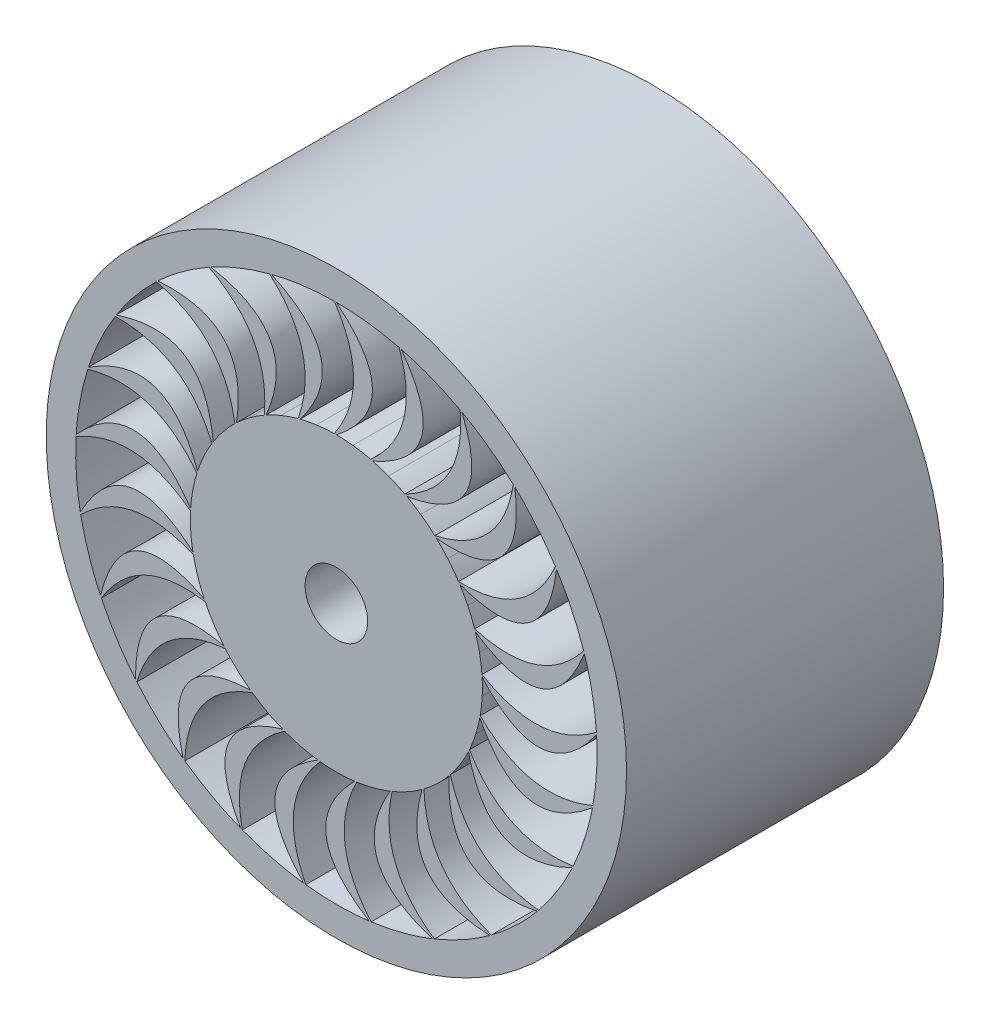
from build123d import *

# Parameters (mm, degrees)
SKETCH1_R           = 70
SKETCH1_R_2         = 50
BOSS_EXTRUDE1_DEPTH = 30
SKETCH2_R           = 70
SKETCH2_R_2         = 34
BOSS_EXTRUDE2_DEPTH = 92
SKETCH3_R           = 70
SKETCH3_R_2         = 15
BOSS_EXTRUDE3_DEPTH = 30
SKETCH5_R           = 139.105411196
SKETCH5_R_2         = 63.215067921
BOSS_EXTRUDE4_DEPTH = 152


with BuildPart() as part:
    # Sketch1 → Boss-Extrude1 (new body)
    with BuildSketch(Plane.XY):
        Circle(SKETCH1_R)
        Circle(SKETCH1_R_2, mode=Mode.SUBTRACT)
    extrude(amount=BOSS_EXTRUDE1_DEPTH)

    # Sketch2 → Boss-Extrude2 (add)
    with BuildSketch(Plane.XY.offset(30)):
        Circle(SKETCH2_R)
        Circle(SKETCH2_R_2, mode=Mode.SUBTRACT)
    extrude(amount=BOSS_EXTRUDE2_DEPTH)

    # Sketch3 → Boss-Extrude3 (add)
    with BuildSketch(Plane.XY.offset(122)):
        Circle(SKETCH3_R)
        Circle(SKETCH3_R_2, mode=Mode.SUBTRACT)
    extrude(amount=BOSS_EXTRUDE3_DEPTH)

    # Sketch5 → Boss-Extrude4 (add)
    with BuildSketch(Plane.XY.offset(152)):
        Circle(SKETCH5_R)
        Circle(SKETCH5_R_2, mode=Mode.SUBTRACT)
        with BuildLine():
            add(Edge.make_bspline(
                [(0, 125), (34.520668481, 97.000437143), (0, 70)],
                knots=[0, 0, 0, 1, 1, 1], degree=2))
            add(Edge.make_bspline(
                [(0, 70), (5.519813502, 69.962422729), (11.084458422, 69.380839885), (16.43970894, 68.049511166)],
                knots=[0.160000001, 0.160000001, 0.160000001, 0.160000001, 0.197721449, 0.197721449, 0.197721449, 0.197721449], degree=3))
            add(Edge.make_bspline(
                [(30.116665724, 121.317708706), (41.090840957, 89.926166343), (16.43970894, 68.049511166)],
                knots=[0, 0, 0, 1, 1, 1], degree=2))
            add(Edge.make_bspline(
                [(0, 125), (15.39585288, 124.97123946), (30.116665724, 121.317708706)],
                knots=[0, 0, 0, 0.0387732, 0.0387732, 0.0387732], degree=2))
        make_face(mode=Mode.SUBTRACT)
        with BuildLine():
            add(Edge.make_bspline(
                [(-0.999992, 124.996), (17.436168466, 97.319847066), (-1, 70)],
                knots=[0, 0, 0, 1, 1, 1], degree=2))
            add(Edge.make_bspline(
                [(-17.408292102, 67.800821279), (-12.052548604, 69.137146364), (-6.518093465, 69.957705932), (-1, 70)],
                knots=[0.120000001, 0.120000001, 0.120000001, 0.120000001, 0.157721449, 0.157721449, 0.157721449, 0.157721449], degree=3))
            add(Edge.make_bspline(
                [(-31.086235896, 121.072895141), (9.313110433, 102.537931188), (-17.408292102, 67.800821279)],
                knots=[0, 0, 0, 1, 1, 1], degree=2))
            add(Edge.make_bspline(
                [(-31.086235896, 121.072895141), (-16.395122569, 124.844074309), (-0.999992, 124.996)],
                knots=[0.961226801, 0.961226801, 0.961226801, 1, 1, 1], degree=2))
        make_face(mode=Mode.SUBTRACT)
        with BuildLine():
            add(Edge.make_bspline(
                [(31.086235896, 121.072895141), (57.559165969, 85.368048889), (17.408292102, 67.800821279)],
                knots=[0, 0, 0, 1, 1, 1], degree=2))
            add(Edge.make_bspline(
                [(17.408292102, 67.800821279), (22.745345426, 66.39170277), (27.990533021, 64.444520503), (32.846450507, 61.823221277)],
                knots=[0.200000001, 0.200000001, 0.200000001, 0.200000001, 0.237721449, 0.237721449, 0.237721449, 0.237721449], degree=3))
            add(Edge.make_bspline(
                [(59.340982578, 110.016579599), (62.163624788, 76.882093864), (32.846450507, 61.823221277)],
                knots=[0, 0, 0, 1, 1, 1], degree=2))
            add(Edge.make_bspline(
                [(31.086235896, 121.072895141), (40.884124984, 118.55665164), (50.438672273, 114.817678972), (59.340982578, 110.016579599)],
                knots=[0.040051117, 0.040051117, 0.040051117, 0.040051117, 0.078824317, 0.078824317, 0.078824317, 0.078824317], degree=3))
        make_face(mode=Mode.SUBTRACT)
        with BuildLine():
            add(Edge.make_bspline(
                [(60.219209263, 109.538335005), (76.981009372, 68.371672162), (33.722757187, 61.341467603)],
                knots=[0, 0, 0, 1, 1, 1], degree=2))
            add(Edge.make_bspline(
                [(33.722757187, 61.341467603), (38.541703642, 58.649347955), (43.137859486, 55.458914889), (47.189328788, 51.712351025)],
                knots=[0.240000001, 0.240000001, 0.240000001, 0.240000001, 0.277721449, 0.277721449, 0.277721449, 0.277721449], degree=3))
            add(Edge.make_bspline(
                [(84.836687257, 91.802704183), (79.330439453, 59.007236675), (47.189328788, 51.712351025)],
                knots=[0, 0, 0, 1, 1, 1], degree=2))
            add(Edge.make_bspline(
                [(60.219209263, 109.538335005), (69.08231109, 104.665148327), (77.408019168, 98.666896079), (84.836687257, 91.802704183)],
                knots=[0.080102234, 0.080102234, 0.080102234, 0.080102234, 0.118875434, 0.118875434, 0.118875434, 0.118875434], degree=3))
        make_face(mode=Mode.SUBTRACT)
        with BuildLine():
            add(Edge.make_bspline(
                [(85.568388241, 91.121078428), (91.56585284, 47.07925182), (47.918297415, 51.027803919)],
                knots=[0, 0, 0, 1, 1, 1], degree=2))
            add(Edge.make_bspline(
                [(47.918297415, 51.027803919), (51.916344875, 47.22183891), (55.574675592, 42.988621687), (58.56712799, 38.352203574)],
                knots=[0.280000001, 0.280000001, 0.280000001, 0.280000001, 0.317721449, 0.317721449, 0.317721449, 0.317721449], degree=3))
            add(Edge.make_bspline(
                [(105.001790868, 67.820527236), (91.512630849, 37.424737791), (58.56712799, 38.352203574)],
                knots=[0, 0, 0, 1, 1, 1], degree=2))
            add(Edge.make_bspline(
                [(85.568388241, 91.121078428), (92.94111503, 84.196834537), (99.513562902, 76.316502684), (105.001790868, 67.820527236)],
                knots=[0.120153351, 0.120153351, 0.120153351, 0.120153351, 0.15892655, 0.15892655, 0.15892655, 0.15892655], degree=3))
        make_face(mode=Mode.SUBTRACT)
        with BuildLine():
            add(Edge.make_bspline(
                [(105.540990688, 66.978349372), (100.397277018, 22.82866894), (59.102954785, 37.507875649)],
                knots=[0, 0, 0, 1, 1, 1], degree=2))
            add(Edge.make_bspline(
                [(59.102954785, 37.507875649), (62.028891223, 32.827208057), (64.51953044, 27.817195284), (66.264939146, 22.582246123)],
                knots=[0.320000001, 0.320000001, 0.320000001, 0.320000001, 0.357721449, 0.357721449, 0.357721449, 0.357721449], degree=3))
            add(Edge.make_bspline(
                [(118.569245789, 39.576937137), (97.94474709, 13.490704994), (66.264939146, 22.582246123)],
                knots=[0, 0, 0, 1, 1, 1], degree=2))
            add(Edge.make_bspline(
                [(105.540990688, 66.978349372), (110.960100153, 58.438120808), (115.36630377, 49.170862689), (118.569245789, 39.576937137)],
                knots=[0.160204467, 0.160204467, 0.160204467, 0.160204467, 0.198977667, 0.198977667, 0.198977667, 0.198977667], degree=3))
        make_face(mode=Mode.SUBTRACT)
        with BuildLine():
            add(Edge.make_bspline(
                [(118.882064537, 38.627124297), (102.920371046, -2.856323167), (66.573956141, 21.631189606)],
                knots=[0, 0, 0, 1, 1, 1], degree=2))
            add(Edge.make_bspline(
                [(66.573956141, 21.631189606), (68.24393421, 16.369922991), (69.410385905, 10.897912197), (69.79908047, 5.393363095)],
                knots=[0.360000001, 0.360000001, 0.360000001, 0.360000001, 0.397721449, 0.397721449, 0.397721449, 0.397721449], degree=3))
            add(Edge.make_bspline(
                [(124.686558929, 8.846582523), (98.222634655, -11.290998413), (69.79908047, 5.393363095)],
                knots=[0, 0, 0, 1, 1, 1], degree=2))
            add(Edge.make_bspline(
                [(118.882064537, 38.627124297), (122.007054234, 29.007524997), (123.970155487, 18.935636551), (124.686558929, 8.846582523)],
                knots=[0.200255584, 0.200255584, 0.200255584, 0.200255584, 0.239028784, 0.239028784, 0.239028784, 0.239028784], degree=3))
        make_face(mode=Mode.SUBTRACT)
        with BuildLine():
            add(Edge.make_bspline(
                [(124.753341054, 7.848814941), (98.976599646, -28.361841984), (69.86187099, 4.395336367)],
                knots=[0, 0, 0, 1, 1, 1], degree=2))
            add(Edge.make_bspline(
                [(69.86187099, 4.395336367), (70.170959827, -1.11594454), (69.939931549, -6.706126793), (68.947488866, -12.13440477)],
                knots=[0.400000001, 0.400000001, 0.400000001, 0.400000001, 0.437721449, 0.437721449, 0.437721449, 0.437721449], degree=3))
            add(Edge.make_bspline(
                [(122.969357008, -22.439635406), (92.328832847, -35.363246864), (68.947488866, -12.13440477)],
                knots=[0, 0, 0, 1, 1, 1], degree=2))
            add(Edge.make_bspline(
                [(124.753341054, 7.848814941), (125.387856388, -2.245720293), (124.784506404, -12.489385272), (122.969357008, -22.439635406)],
                knots=[0.240306701, 0.240306701, 0.240306701, 0.240306701, 0.2790799, 0.2790799, 0.2790799, 0.2790799], degree=3))
        make_face(mode=Mode.SUBTRACT)
        with BuildLine():
            add(Edge.make_bspline(
                [(122.785906341, -23.422664323), (88.81376448, -52.085281962), (68.760107551, -13.116692021)],
                knots=[0, 0, 0, 1, 1, 1], degree=2))
            add(Edge.make_bspline(
                [(68.760107551, -13.116692021), (67.688885967, -18.531693172), (66.074894073, -23.888795174), (63.763672964, -28.899723357)],
                knots=[0.440000001, 0.440000001, 0.440000001, 0.440000001, 0.477721449, 0.477721449, 0.477721449, 0.477721449], degree=3))
            add(Edge.make_bspline(
                [(113.525538135, -52.315888515), (80.63367091, -57.213492459), (63.763672964, -28.899723357)],
                knots=[0, 0, 0, 1, 1, 1], degree=2))
            add(Edge.make_bspline(
                [(122.785906341, -23.422664323), (120.890078381, -33.357858717), (117.758187859, -43.129653084), (113.525538135, -52.315888515)],
                knots=[0.280357817, 0.280357817, 0.280357817, 0.280357817, 0.319131017, 0.319131017, 0.319131017, 0.319131017], degree=3))
        make_face(mode=Mode.SUBTRACT)
        with BuildLine():
            add(Edge.make_bspline(
                [(113.103381558, -53.222411446), (73.070433857, -72.536012119), (63.337893673, -29.80455041)],
                knots=[0, 0, 0, 1, 1, 1], degree=2))
            add(Edge.make_bspline(
                [(63.337893673, -29.80455041), (60.953670459, -34.783027367), (58.058127997, -39.570442697), (54.573350984, -43.84916604)],
                knots=[0.480000001, 0.480000001, 0.480000001, 0.480000001, 0.517721449, 0.517721449, 0.517721449, 0.517721449], degree=3))
            add(Edge.make_bspline(
                [(96.948492184, -78.904941944), (63.87199888, -75.468803905), (54.573350984, -43.84916604)],
                knots=[0, 0, 0, 1, 1, 1], degree=2))
            add(Edge.make_bspline(
                [(113.103381558, -53.222411446), (108.796332147, -62.374000197), (103.332689286, -71.059926174), (96.948492184, -78.904941944)],
                knots=[0.320408934, 0.320408934, 0.320408934, 0.320408934, 0.359182134, 0.359182134, 0.359182134, 0.359182134], degree=3))
        make_face(mode=Mode.SUBTRACT)
        with BuildLine():
            add(Edge.make_bspline(
                [(96.314155347, -79.677998719), (52.735819142, -88.429037865), (53.935926994, -44.619679282)],
                knots=[0, 0, 0, 1, 1, 1], degree=2))
            add(Edge.make_bspline(
                [(53.935926994, -44.619679282), (50.388511665, -48.848816029), (46.393356215, -52.765733775), (41.953984655, -56.043404354)],
                knots=[0.520000001, 0.520000001, 0.520000001, 0.520000001, 0.557721449, 0.557721449, 0.557721449, 0.557721449], degree=3))
            add(Edge.make_bspline(
                [(74.279815918, -100.536107679), (43.097014255, -88.982132847), (41.953984655, -56.043404354)],
                knots=[0, 0, 0, 1, 1, 1], degree=2))
            add(Edge.make_bspline(
                [(96.314155347, -79.677998719), (89.866512239, -87.470953849), (82.414417813, -94.525242763), (74.279815918, -100.536107679)],
                knots=[0.360460051, 0.360460051, 0.360460051, 0.360460051, 0.39923325, 0.39923325, 0.39923325, 0.39923325], degree=3))
        make_face(mode=Mode.SUBTRACT)
        with BuildLine():
            add(Edge.make_bspline(
                [(73.473156537, -101.127124297), (29.08761896, -98.765741942), (41.14496766, -56.631189606)],
                knots=[0, 0, 0, 1, 1, 1], degree=2))
            add(Edge.make_bspline(
                [(41.14496766, -56.631189606), (36.657257366, -59.845253927), (31.813519239, -62.645559741), (26.698495174, -64.716229459)],
                knots=[0.560000001, 0.560000001, 0.560000001, 0.560000001, 0.597721449, 0.597721449, 0.597721449, 0.597721449], degree=3))
            add(Edge.make_bspline(
                [(46.943865635, -115.850220022), (19.614085725, -96.904387129), (26.698495174, -64.716229459)],
                knots=[0, 0, 0, 1, 1, 1], degree=2))
            add(Edge.make_bspline(
                [(73.473156537, -101.127124297), (65.290048862, -107.071785774), (56.317745373, -112.051190708), (46.943865635, -115.850220022)],
                knots=[0.400511167, 0.400511167, 0.400511167, 0.400511167, 0.439284367, 0.439284367, 0.439284367, 0.439284367], degree=3))
        make_face(mode=Mode.SUBTRACT)
        with BuildLine():
            add(Edge.make_bspline(
                [(46.015569086, -116.222060736), (3.611736703, -102.896631219), (25.768718688, -65.084354012)],
                knots=[0, 0, 0, 1, 1, 1], degree=2))
            add(Edge.make_bspline(
                [(25.768718688, -65.084354012), (20.622692772, -67.081394426), (15.234721848, -68.589134795), (9.765441051, -69.322695858)],
                knots=[0.600000001, 0.600000001, 0.600000001, 0.600000001, 0.637721449, 0.637721449, 0.637721449, 0.637721449], degree=3))
            add(Edge.make_bspline(
                [(16.658259627, -123.885036975), (-5.101267947, -98.737782379), (9.765441051, -69.322695858)],
                knots=[0, 0, 0, 1, 1, 1], degree=2))
            add(Edge.make_bspline(
                [(46.015569086, -116.222060736), (36.611171594, -119.944903617), (26.682421867, -122.536550246), (16.658259627, -123.885036975)],
                knots=[0.440562284, 0.440562284, 0.440562284, 0.440562284, 0.479335484, 0.479335484, 0.479335484, 0.479335484], degree=3))
        make_face(mode=Mode.SUBTRACT)
        with BuildLine():
            add(Edge.make_bspline(
                [(15.666654196, -124.014337664), (-22.091084255, -100.562146729), (8.77332635, -69.448029092)],
                knots=[0, 0, 0, 1, 1, 1], degree=2))
            add(Edge.make_bspline(
                [(8.77332635, -69.448029092), (3.292328545, -70.102564204), (-2.301329147, -70.223002256), (-7.781211648, -69.573362326)],
                knots=[0.640000001, 0.640000001, 0.640000001, 0.640000001, 0.677721449, 0.677721449, 0.677721449, 0.677721449], degree=3))
            add(Edge.make_bspline(
                [(-14.674046098, -124.135701436), (-29.496090193, -94.367119629), (-7.781211648, -69.573362326)],
                knots=[0, 0, 0, 1, 1, 1], degree=2))
            add(Edge.make_bspline(
                [(15.666654196, -124.014337664), (5.631879766, -125.28144204), (-4.629456336, -125.322487675), (-14.674046098, -124.135701436)],
                knots=[0.480613401, 0.480613401, 0.480613401, 0.480613401, 0.5193866, 0.5193866, 0.5193866, 0.5193866], degree=3))
        make_face(mode=Mode.SUBTRACT)
        with BuildLine():
            add(Edge.make_bspline(
                [(-15.666654196, -124.014337664), (-46.405841143, -91.908972718), (-8.77332635, -69.448029092)],
                knots=[0, 0, 0, 1, 1, 1], degree=2))
            add(Edge.make_bspline(
                [(-8.77332635, -69.448029092), (-14.244904792, -68.718932054), (-19.692779167, -67.444500223), (-24.838942202, -65.452478565)],
                knots=[0.680000001, 0.680000001, 0.680000001, 0.680000001, 0.717721449, 0.717721449, 0.717721449, 0.717721449], degree=3))
            add(Edge.make_bspline(
                [(-45.08432754, -116.586463238), (-52.037564612, -84.067023695), (-24.838942202, -65.452478565)],
                knots=[0, 0, 0, 1, 1, 1], degree=2))
            add(Edge.make_bspline(
                [(-15.666654196, -124.014337664), (-25.701283776, -122.746086706), (-35.650448771, -120.233952299), (-45.08432754, -116.586463238)],
                knots=[0.520664518, 0.520664518, 0.520664518, 0.520664518, 0.559437717, 0.559437717, 0.559437717, 0.559437717], degree=3))
        make_face(mode=Mode.SUBTRACT)
        with BuildLine():
            add(Edge.make_bspline(
                [(-46.015569086, -116.222060736), (-67.804748364, -77.480819933), (-25.768718688, -65.084354012)],
                knots=[0, 0, 0, 1, 1, 1], degree=2))
            add(Edge.make_bspline(
                [(-25.768718688, -65.084354012), (-30.887078372, -63.017436673), (-35.846859447, -60.428212198), (-40.335950666, -57.218974859)],
                knots=[0.720000001, 0.720000001, 0.720000001, 0.720000001, 0.757721449, 0.757721449, 0.757721449, 0.757721449], degree=3))
            add(Edge.make_bspline(
                [(-72.661794873, -101.711668779), (-71.309327467, -68.484687485), (-40.335950666, -57.218974859)],
                knots=[0, 0, 0, 1, 1, 1], degree=2))
            add(Edge.make_bspline(
                [(-46.015569086, -116.222060736), (-55.419541137, -112.498143315), (-64.431392397, -107.59067551), (-72.661794873, -101.711668779)],
                knots=[0.560715634, 0.560715634, 0.560715634, 0.560715634, 0.599488834, 0.599488834, 0.599488834, 0.599488834], degree=3))
        make_face(mode=Mode.SUBTRACT)
        with BuildLine():
            add(Edge.make_bspline(
                [(-73.473156537, -101.127124297), (-84.943233876, -58.184262278), (-41.14496766, -56.631189606)],
                knots=[0, 0, 0, 1, 1, 1], degree=2))
            add(Edge.make_bspline(
                [(-41.14496766, -56.631189606), (-45.588503223, -53.356323984), (-49.748549713, -49.614997361), (-53.298503005, -45.390192525)],
                knots=[0.760000001, 0.760000001, 0.760000001, 0.760000001, 0.797721449, 0.797721449, 0.797721449, 0.797721449], degree=3))
            add(Edge.make_bspline(
                [(-95.673654404, -80.445956101), (-86.100463019, -48.599206492), (-53.298503005, -45.390192525)],
                knots=[0, 0, 0, 1, 1, 1], degree=2))
            add(Edge.make_bspline(
                [(-73.473156537, -101.127124297), (-81.65558491, -95.181527841), (-89.163874678, -88.187080886), (-95.673654404, -80.445956101)],
                knots=[0.600766751, 0.600766751, 0.600766751, 0.600766751, 0.63953995, 0.63953995, 0.63953995, 0.63953995], degree=3))
        make_face(mode=Mode.SUBTRACT)
        with BuildLine():
            add(Edge.make_bspline(
                [(-96.314155347, -79.677998719), (-96.744423605, -35.231773437), (-53.935926994, -44.619679282)],
                knots=[0, 0, 0, 1, 1, 1], degree=2))
            add(Edge.make_bspline(
                [(-53.935926994, -44.619679282), (-57.425434754, -40.342637228), (-60.524355638, -35.684289769), (-62.912114381, -30.709377462)],
                knots=[0.800000001, 0.800000001, 0.800000001, 0.800000001, 0.837721449, 0.837721449, 0.837721449, 0.837721449], degree=3))
            add(Edge.make_bspline(
                [(-112.673986365, -54.125528142), (-95.481589824, -25.660058619), (-62.912114381, -30.709377462)],
                knots=[0, 0, 0, 1, 1, 1], degree=2))
            add(Edge.make_bspline(
                [(-96.314155347, -79.677998719), (-102.760907978, -71.884306916), (-108.293862784, -63.242367653), (-112.673986365, -54.125528142)],
                knots=[0.640817868, 0.640817868, 0.640817868, 0.640817868, 0.679591067, 0.679591067, 0.679591067, 0.679591067], degree=3))
        make_face(mode=Mode.SUBTRACT)
        with BuildLine():
            add(Edge.make_bspline(
                [(-113.103381558, -53.222411446), (-102.466805398, -10.065542697), (-63.337893673, -29.80455041)],
                knots=[0, 0, 0, 1, 1, 1], degree=2))
            add(Edge.make_bspline(
                [(-63.337893673, -29.80455041), (-65.654115024, -24.794074205), (-67.497193705, -19.511407012), (-68.572726236, -14.098979272)],
                knots=[0.840000001, 0.840000001, 0.840000001, 0.840000001, 0.877721449, 0.877721449, 0.877721449, 0.877721449], degree=3))
            add(Edge.make_bspline(
                [(-122.594597377, -24.40419419), (-98.863257184, -1.108594893), (-68.572726236, -14.098979272)],
                knots=[0, 0, 0, 1, 1, 1], degree=2))
            add(Edge.make_bspline(
                [(-113.103381558, -53.222411446), (-117.409385262, -44.070330626), (-120.619349224, -34.323903852), (-122.594597377, -24.40419419)],
                knots=[0.680868984, 0.680868984, 0.680868984, 0.680868984, 0.719642184, 0.719642184, 0.719642184, 0.719642184], degree=3))
        make_face(mode=Mode.SUBTRACT)
        with BuildLine():
            add(Edge.make_bspline(
                [(-122.785906341, -23.422664323), (-101.750820961, 15.733143108), (-68.760107551, -13.116692021)],
                knots=[0, 0, 0, 1, 1, 1], degree=2))
            add(Edge.make_bspline(
                [(-68.760107551, -13.116692021), (-69.757505787, -7.687608313), (-70.228934855, -2.112550796), (-69.92466151, 3.397309639)],
                knots=[0.880000001, 0.880000001, 0.880000001, 0.880000001, 0.917721449, 0.917721449, 0.917721449, 0.917721449], degree=3))
            add(Edge.make_bspline(
                [(-124.812138964, 6.850545035), (-96.032982502, 23.512525928), (-69.92466151, 3.397309639)],
                knots=[0, 0, 0, 1, 1, 1], degree=2))
            add(Edge.make_bspline(
                [(-122.785906341, -23.422664323), (-124.680599075, -13.487253369), (-125.365878341, -3.248742957), (-124.812138964, 6.850545035)],
                knots=[0.720920101, 0.720920101, 0.720920101, 0.720920101, 0.7596933, 0.7596933, 0.7596933, 0.7596933], degree=3))
        make_face(mode=Mode.SUBTRACT)
        with BuildLine():
            add(Edge.make_bspline(
                [(-124.753341054, 7.848814941), (-94.641458229, 40.54325767), (-69.86187099, 4.395336367)],
                knots=[0, 0, 0, 1, 1, 1], degree=2))
            add(Edge.make_bspline(
                [(-69.86187099, 4.395336367), (-69.477775912, 9.901898281), (-68.547933743, 15.419044758), (-66.882973135, 20.68013309)],
                knots=[0.920000001, 0.920000001, 0.920000001, 0.920000001, 0.957721449, 0.957721449, 0.957721449, 0.957721449], degree=3))
            add(Edge.make_bspline(
                [(-119.187274833, 37.674839321), (-87.168602344, 46.656268272), (-66.882973135, 20.68013309)],
                knots=[0, 0, 0, 1, 1, 1], degree=2))
            add(Edge.make_bspline(
                [(-124.753341054, 7.848814941), (-124.117672303, 17.943277604), (-122.235208259, 28.030548424), (-119.187274833, 37.674839321)],
                knots=[0.760971218, 0.760971218, 0.760971218, 0.760971218, 0.799744417, 0.799744417, 0.799744417, 0.799744417], degree=3))
        make_face(mode=Mode.SUBTRACT)
        with BuildLine():
            add(Edge.make_bspline(
                [(-118.882064537, 38.627124297), (-81.58542461, 62.805890244), (-66.573956141, 21.631189606)],
                knots=[0, 0, 0, 1, 1, 1], degree=2))
            add(Edge.make_bspline(
                [(-66.573956141, 21.631189606), (-64.832501855, 26.86923219), (-62.559813851, 31.981805023), (-59.63878158, 36.663547723)],
                knots=[0.960000001, 0.960000001, 0.960000001, 0.960000001, 0.997721449, 0.997721449, 0.997721449, 0.997721449], degree=3))
            add(Edge.make_bspline(
                [(-106.073435884, 66.131884894), (-72.827098317, 66.868425691), (-59.63878158, 36.663547723)],
                knots=[0, 0, 0, 1, 1, 1], degree=2))
            add(Edge.make_bspline(
                [(-118.882064537, 38.627124297), (-115.755975708, 48.246366467), (-111.424050493, 57.54857735), (-106.073435884, 66.131884894)],
                knots=[0.801022334, 0.801022334, 0.801022334, 0.801022334, 0.839795534, 0.839795534, 0.839795534, 0.839795534], degree=3))
        make_face(mode=Mode.SUBTRACT)
        with BuildLine():
            add(Edge.make_bspline(
                [(-105.540990688, 66.978349372), (-63.403078713, 81.122197751), (-59.102954785, 37.507875649)],
                knots=[0, 0, 0, 1, 1, 1], degree=2))
            add(Edge.make_bspline(
                [(-59.102954785, 37.507875649), (-56.113563263, 42.14827343), (-52.640830932, 46.535030708), (-48.647266042, 50.343256814)],
                knots=[0, 0, 0, 0, 0.037721449, 0.037721449, 0.037721449, 0.037721449], degree=3))
            add(Edge.make_bspline(
                [(-86.294612848, 90.433620924), (-53.909599864, 82.878993999), (-48.647266042, 50.343256814)],
                knots=[0, 0, 0, 1, 1, 1], degree=2))
            add(Edge.make_bspline(
                [(-105.540990688, 66.978349372), (-100.12090544, 75.517958682), (-93.61170998, 83.450617479), (-86.294612848, 90.433620924)],
                knots=[0.841073451, 0.841073451, 0.841073451, 0.841073451, 0.87984665, 0.87984665, 0.87984665, 0.87984665], degree=3))
        make_face(mode=Mode.SUBTRACT)
        with BuildLine():
            add(Edge.make_bspline(
                [(-85.568388241, 91.121078428), (-41.2368842, 94.341299226), (-47.918297415, 51.027803919)],
                knots=[0, 0, 0, 1, 1, 1], degree=2))
            add(Edge.make_bspline(
                [(-47.918297415, 51.027803919), (-43.868803131, 54.778983626), (-39.414230709, 58.164289554), (-34.599063867, 60.859713929)],
                knots=[0.040000001, 0.040000001, 0.040000001, 0.040000001, 0.077721449, 0.077721449, 0.077721449, 0.077721449], degree=3))
            add(Edge.make_bspline(
                [(-61.093581918, 109.053079959), (-31.604762986, 93.681970306), (-34.599063867, 60.859713929)],
                knots=[0, 0, 0, 1, 1, 1], degree=2))
            add(Edge.make_bspline(
                [(-85.568388241, 91.121078428), (-78.194870741, 98.04447975), (-69.917414675, 104.109145125), (-61.093581918, 109.053079959)],
                knots=[0.881124568, 0.881124568, 0.881124568, 0.881124568, 0.919897767, 0.919897767, 0.919897767, 0.919897767], degree=3))
        make_face(mode=Mode.SUBTRACT)
        with BuildLine():
            add(Edge.make_bspline(
                [(-60.219209263, 109.538335005), (-16.479624594, 101.632589908), (-33.722757187, 61.341467603)],
                knots=[0, 0, 0, 1, 1, 1], degree=2))
            add(Edge.make_bspline(
                [(-33.722757187, 61.341467603), (-28.867604755, 63.967728824), (-23.711089567, 66.138872029), (-18.376875263, 67.552131392)],
                knots=[0.080000001, 0.080000001, 0.080000001, 0.080000001, 0.117721449, 0.117721449, 0.117721449, 0.117721449], degree=3))
            add(Edge.make_bspline(
                [(-32.053816548, 120.820332911), (-7.314082615, 98.59856388), (-18.376875263, 67.552131392)],
                knots=[0, 0, 0, 1, 1, 1], degree=2))
            add(Edge.make_bspline(
                [(-60.219209263, 109.538335005), (-51.355592047, 114.410498806), (-41.831262019, 118.225787522), (-32.053816548, 120.820332911)],
                knots=[0.921175684, 0.921175684, 0.921175684, 0.921175684, 0.959948884, 0.959948884, 0.959948884, 0.959948884], degree=3))
        make_face(mode=Mode.SUBTRACT)
    extrude(amount=-BOSS_EXTRUDE4_DEPTH)


solid = part.part
